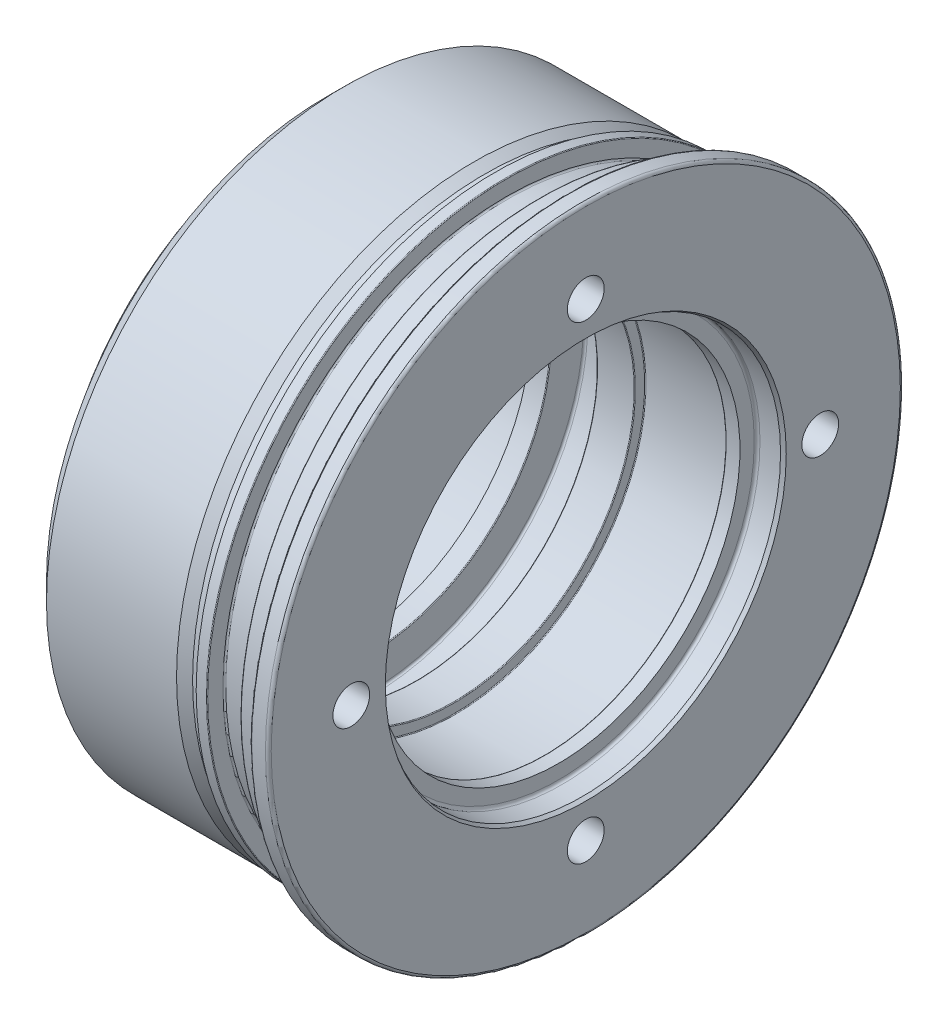
from build123d import *

# Parameters (mm, degrees)
F_4_STK_10_2_X_12_HULLER_D     = 10.2
F_4_STK_10_2_X_12_HULLER_DEPTH = 12
F_4_STK_10_2_X_12_HULLER_TIP   = 3.064389157


with BuildPart() as part:
    # Sketch1 → Base-Revolve (revolve)
    with BuildSketch(Plane.XY):
        with BuildLine():
            Line((0, 55.577350269), (0, 87.2))
            ThreePointArc((0, 87.2), (-0.234314575, 87.765685425), (-0.8, 88))
            Line((-0.8, 88), (-4.6, 88))
            ThreePointArc((-4.6, 88), (-4.882842712, 87.882842712), (-5, 87.6))
            Line((-5, 87.6), (-5, 83.8))
            ThreePointArc((-5, 83.8), (-5.234314575, 83.234314575), (-5.8, 83))
            Line((-5.8, 83), (-12.5, 83))
            ThreePointArc((-12.5, 83), (-12.641421356, 82.941421356), (-12.7, 82.8))
            Line((-12.7, 82.8), (-12.7, 78.6))
            ThreePointArc((-12.7, 78.6), (-12.817157288, 78.317157288), (-13.1, 78.2))
            Line((-13.1, 78.2), (-21.6, 78.2))
            ThreePointArc((-21.6, 78.2), (-21.882842712, 78.317157288), (-22, 78.6))
            Line((-22, 78.6), (-22, 82.8))
            ThreePointArc((-22, 82.8), (-22.058578644, 82.941421356), (-22.2, 83))
            Line((-22.2, 83), (-25, 83))
            Line((-25, 83), (-25, 81))
            Line((-25, 81), (-28, 81))
            Line((-28, 81), (-30.943915758, 82.5))
            Line((-30.943915758, 82.5), (-67, 82.5))
            Line((-67, 82.5), (-72, 77.5))
            Line((-72, 77.5), (-72, 70))
            Line((-72, 70), (-77.5, 70))
            Line((-77.5, 70), (-77.5, 52))
            Line((-77.5, 52), (-65.5, 52))
            Line((-65.5, 52), (-65.5, 50.25))
            Line((-65.5, 50.25), (-60.2, 50.25))
            ThreePointArc((-60.2, 50.25), (-60.058578644, 50.308578644), (-60, 50.45))
            Line((-60, 50.45), (-60, 59.4))
            ThreePointArc((-60, 59.4), (-59.824264069, 59.824264069), (-59.4, 60))
            Line((-59.4, 60), (-47.6, 60))
            ThreePointArc((-47.6, 60), (-47.175735931, 59.824264069), (-47, 59.4))
            Line((-47, 59.4), (-47, 50.3))
            ThreePointArc((-47, 50.3), (-46.941421356, 50.158578644), (-46.8, 50.1))
            Line((-46.8, 50.1), (-36.7, 50.1))
            ThreePointArc((-36.7, 50.1), (-36.558578644, 50.158578644), (-36.5, 50.3))
            Line((-36.5, 50.3), (-36.5, 52.8))
            ThreePointArc((-36.5, 52.8), (-36.441421356, 52.941421356), (-36.3, 53))
            Line((-36.3, 53), (-11.7, 53))
            ThreePointArc((-11.7, 53), (-11.558578644, 52.941421356), (-11.5, 52.8))
            Line((-11.5, 52.8), (-11.5, 50.45))
            ThreePointArc((-11.5, 50.45), (-11.441421356, 50.308578644), (-11.3, 50.25))
            Line((-11.3, 50.25), (-7.5, 50.25))
            Line((-7.5, 50.25), (-7.5, 54.2))
            ThreePointArc((-7.5, 54.2), (-7.265685425, 54.765685425), (-6.7, 55))
            Line((-6.7, 55), (-1, 55))
            Line((-1, 55), (0, 55.577350269))
        make_face()
    revolve(axis=Axis((-77.5, 0, 0), (1, 0, 0)))

    # 4 stk ø10.2 x 12 huller
    with Locations(Plane(origin=(0, 0, 0), x_dir=(0, 0, -1), z_dir=(1, 0, 0))):
        with Locations((0, 65), (65, 0), (0, -65), (-65, 0)):
            Hole(F_4_STK_10_2_X_12_HULLER_D / 2, depth=F_4_STK_10_2_X_12_HULLER_DEPTH)
            with Locations((0, 0, -(F_4_STK_10_2_X_12_HULLER_DEPTH + F_4_STK_10_2_X_12_HULLER_TIP / 2))):  # 118° drill point
                Cone(0, F_4_STK_10_2_X_12_HULLER_D / 2, F_4_STK_10_2_X_12_HULLER_TIP, mode=Mode.SUBTRACT)


solid = part.part
